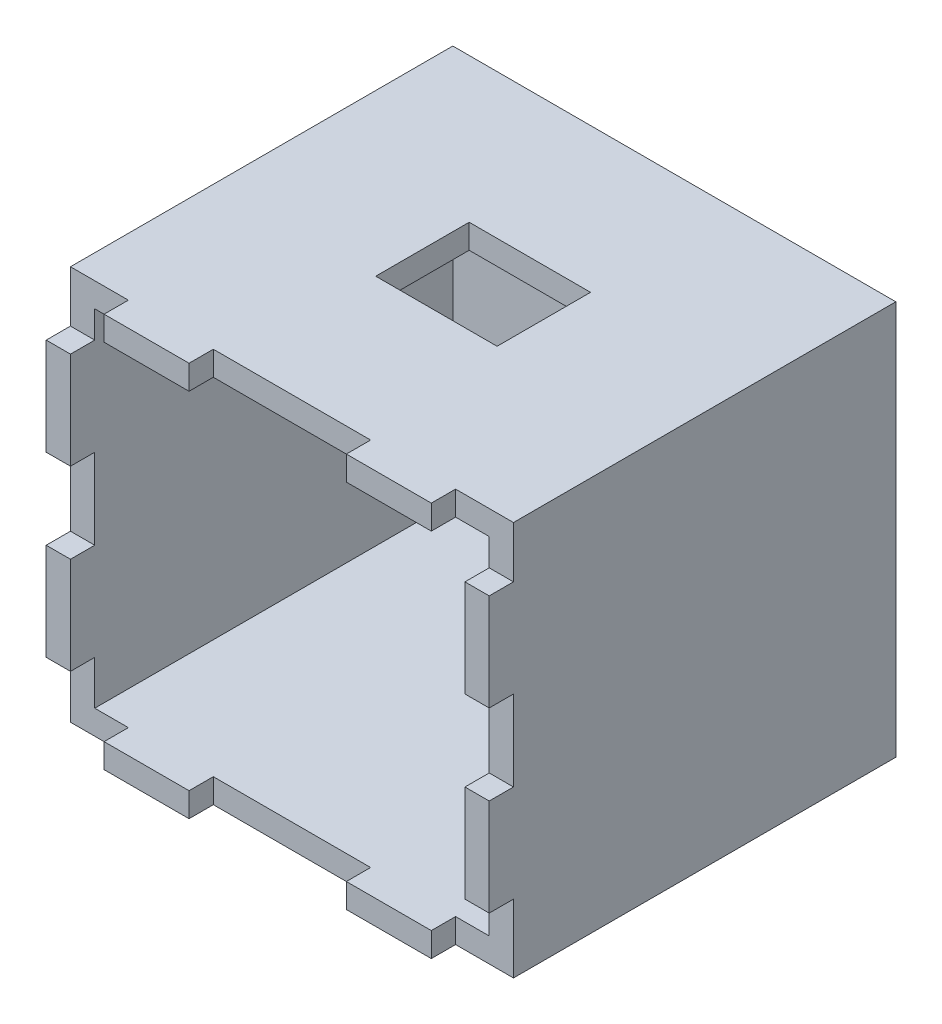
from build123d import *

# Parameters (mm, degrees)
ESBO_O1_W                = 36.5
ESBO_O1_H                = 32.5
ESBO_O1_W_2              = 32.5
ESBO_O1_H_2              = 28.5
RESSALTO_EXTRUS_O1_DEPTH = 29.5
ESBO_O1_3_W              = 7
ESBO_O1_3_H              = 2
ESBO_O1_3_W_2            = 2
ESBO_O1_3_H_2            = 8
RESSALTO_EXTRUS_O2_DEPTH = 31.5
ESBO_O1_4_W              = 36.5
ESBO_O1_4_H              = 32.5
RESSALTO_EXTRUS_O3_DEPTH = 2
ESBO_O2_W                = 10
ESBO_O2_H                = 7.7
CORTE_EXTRUS_O1_DEPTH    = 43.237292821


with BuildPart() as part:
    # Esboço1 → Ressalto-extrusão1 (new body)
    with BuildSketch(Plane.XY):
        with Locations((0.585584979, -4.653579677)):
            Rectangle(ESBO_O1_W, ESBO_O1_H)
        with Locations((0.585584979, -4.653579677)):
            Rectangle(ESBO_O1_W_2, ESBO_O1_H_2, mode=Mode.SUBTRACT)
    extrude(amount=RESSALTO_EXTRUS_O1_DEPTH)

    # Esboço1<3> → Ressalto-extrusão2 (add)
    with BuildSketch(Plane.XY):
        with Locations((-9.394784536, 10.596420323)):
            Rectangle(ESBO_O1_3_W, ESBO_O1_3_H)
        with Locations((-16.664415021, 3.362009238)):
            Rectangle(ESBO_O1_3_W_2, ESBO_O1_3_H_2)
        with Locations((10.565584979, 10.596420323)):
            Rectangle(ESBO_O1_3_W, ESBO_O1_3_H)
        with Locations((-16.664415021, -11.274249423)):
            Rectangle(ESBO_O1_3_W_2, ESBO_O1_3_H_2)
        with Locations((17.835584979, 3.362009238)):
            Rectangle(ESBO_O1_3_W_2, ESBO_O1_3_H_2)
        with Locations((-9.394415021, -19.903579677)):
            Rectangle(ESBO_O1_3_W, ESBO_O1_3_H)
        with Locations((17.835584979, -11.274249423)):
            Rectangle(ESBO_O1_3_W_2, ESBO_O1_3_H_2)
        with Locations((10.565584979, -19.903579677)):
            Rectangle(ESBO_O1_3_W, ESBO_O1_3_H)
    extrude(amount=RESSALTO_EXTRUS_O2_DEPTH)

    # Esboço1<4> → Ressalto-extrusão3 (add)
    with BuildSketch(Plane.XY):
        with Locations((0.585584979, -4.653579677)):
            Rectangle(ESBO_O1_4_W, ESBO_O1_4_H)
    extrude(amount=-RESSALTO_EXTRUS_O3_DEPTH)

    # Esboço2 → Corte-extrusão1 (cut, through all)
    with BuildSketch(Plane(origin=(0, 0, 0), x_dir=(1, 0, 0), z_dir=(0, 1, 0))):
        with Locations((0.585584979, -13.75)):
            Rectangle(ESBO_O2_W, ESBO_O2_H)
    extrude(amount=CORTE_EXTRUS_O1_DEPTH, mode=Mode.SUBTRACT)


solid = part.part
